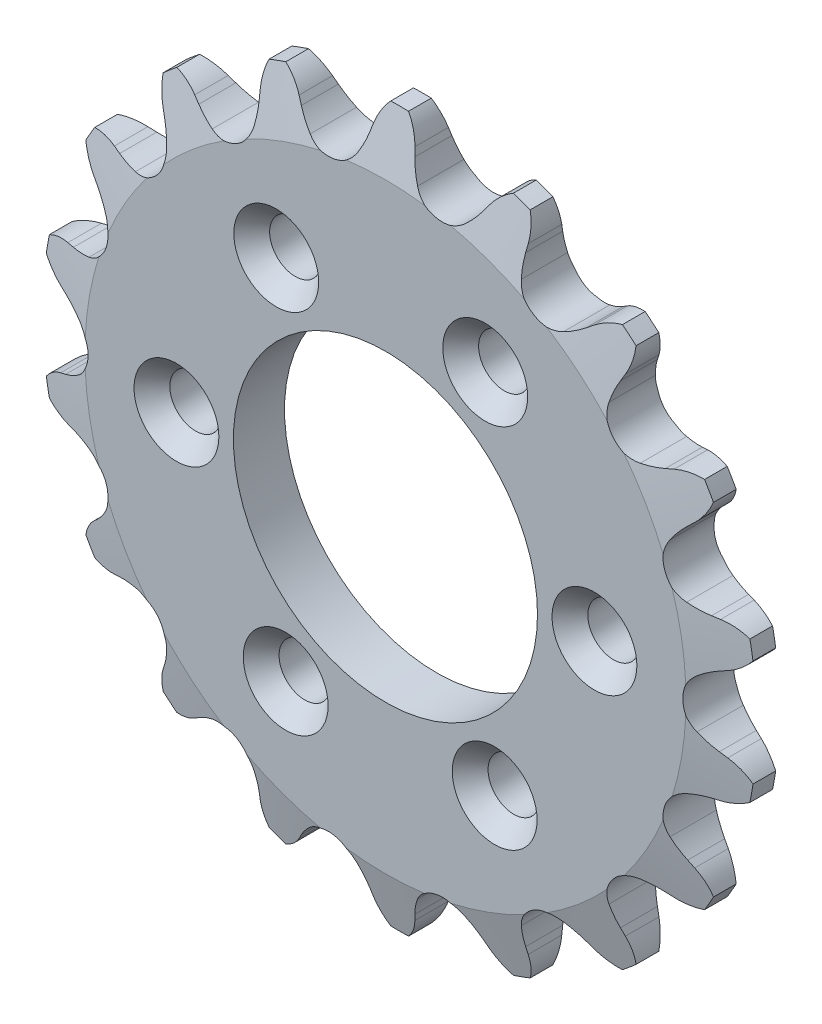
from build123d import *

# Parameters (mm, degrees)
CUT_EXTRUDE1_DEPTH                             = 43.292141087
CIRPATTERN1_COUNT                              = 18
CUT_EXTRUDE2_DEPTH                             = 43.054941547
CUT_EXTRUDE2_DEPTH_BACK                        = 43.054941547
SKETCH3_OUTSIDE_W                              = 77.882
SKETCH3_OUTSIDE_H                              = 78.556
SKETCH3_OUTSIDE_R                              = 29.845
SKETCH3_OUTSIDE_R_2                            = 6.35
SKETCH4_R                                      = 12.7
CUT_EXTRUDE3_DEPTH                             = 43.188466737
CSK_FOR_6_FLAT_HEAD_MACHINE_SCREW1_D           = 4.3053
CSK_FOR_6_FLAT_HEAD_MACHINE_SCREW1_CSINK_D     = 7.0866
CSK_FOR_6_FLAT_HEAD_MACHINE_SCREW1_CSINK_ANGLE = 82
CIRPATTERN2_COUNT                              = 6


with BuildPart() as part:
    # Sketch1 → Revolve1 (revolve)
    with BuildSketch(Plane(origin=(0, 0, 0), x_dir=(0, 0, -1), z_dir=(1, 0, 0)), mode=Mode.PRIVATE) as revolve1_sk:
        Polygon((2.1336, 0), (-2.1336, 0), (-2.1336, 25.104479666), (-0.942975, 29.866979666), (0.942975, 29.866979666), (2.1336, 25.104479666), align=None)
    revolve(revolve1_sk.sketch.rotate(Axis((0, 0, -2.1336), (0, 0, 1)), 90), axis=Axis((0, 0, -2.1336), (0, 0, 1)))

    # Sketch0 → Cut-Extrude1 (cut, symmetric)
    with BuildSketch(Plane.XY):
        with BuildLine():
            Line((7.949491396, -26.886180298), (7.613671832, -26.377741827))
            ThreePointArc((7.613671832, -26.377741827), (7.09166814, -25.689195926), (6.484853129, -25.074087111))
            ThreePointArc((6.484853129, -25.074087111), (4.312612301, -24.458039739), (2.482074236, -25.779885028))
            ThreePointArc((2.482074236, -25.779885028), (2.122234252, -26.565441199), (1.867207802, -27.390998479))
            Line((1.867207802, -27.390998479), (1.725536835, -27.983631414))
            ThreePointArc((1.725536835, -27.983631414), (0.100914937, -30.408062234), (-2.712595967, -31.183573358))
            ThreePointArc((-2.712595967, -31.183573358), (5.435419369, -30.825795052), (13.214416643, -28.375211313))
            ThreePointArc((13.214416643, -28.375211313), (10.305340782, -28.608746635), (7.949491396, -26.886180298))
        make_face()
    cut_extrude1 = extrude(amount=CUT_EXTRUDE1_DEPTH, both=True, mode=Mode.SUBTRACT)

    # CirPattern1: Cut-Extrude1 ×18 about axis
    cirpattern1_axis = Axis((0, 0, 0), (0, 0, 1))
    for i in range(1, CIRPATTERN1_COUNT):
        add(cut_extrude1.rotate(cirpattern1_axis, i * 360 / CIRPATTERN1_COUNT), mode=Mode.SUBTRACT)

    # Sketch3 outside → Cut-Extrude2 (cut, two sides: drawn at the far end of the back side and taken through both)
    # profile 1 of 2: a face of its own
    with BuildSketch(Plane.XY.offset(-CUT_EXTRUDE2_DEPTH_BACK)):
        Rectangle(SKETCH3_OUTSIDE_W, SKETCH3_OUTSIDE_H)
        Circle(SKETCH3_OUTSIDE_R, mode=Mode.SUBTRACT)
    # profile 2 of 2: a face of its own
    with BuildSketch(Plane.XY.offset(-CUT_EXTRUDE2_DEPTH_BACK)):
        Circle(SKETCH3_OUTSIDE_R_2)
    extrude(amount=CUT_EXTRUDE2_DEPTH + CUT_EXTRUDE2_DEPTH_BACK, mode=Mode.SUBTRACT)

    # Sketch4 → Cut-Extrude3 (cut, through all)
    with BuildSketch(Plane.XY.offset(2.1336)):
        Circle(SKETCH4_R)
    extrude(amount=-CUT_EXTRUDE3_DEPTH, mode=Mode.SUBTRACT)

    # CSK for #6 Flat Head Machine Screw1 (through all)
    with Locations(Plane.XY.offset(2.1336)):
        with Locations((17.456554717, 0.455635463)):
            csk_for_6_flat_head_machine_screw1 = CounterSinkHole(CSK_FOR_6_FLAT_HEAD_MACHINE_SCREW1_D / 2, CSK_FOR_6_FLAT_HEAD_MACHINE_SCREW1_CSINK_D / 2, counter_sink_angle=CSK_FOR_6_FLAT_HEAD_MACHINE_SCREW1_CSINK_ANGLE)

    # CirPattern2: CSK for #6 Flat Head Machine Screw1 ×6 about axis
    cirpattern2_axis = Axis((0, 0, 0), (0, 0, 1))
    for i in range(1, CIRPATTERN2_COUNT):
        add(csk_for_6_flat_head_machine_screw1.rotate(cirpattern2_axis, i * 360 / CIRPATTERN2_COUNT), mode=Mode.SUBTRACT)


solid = part.part
